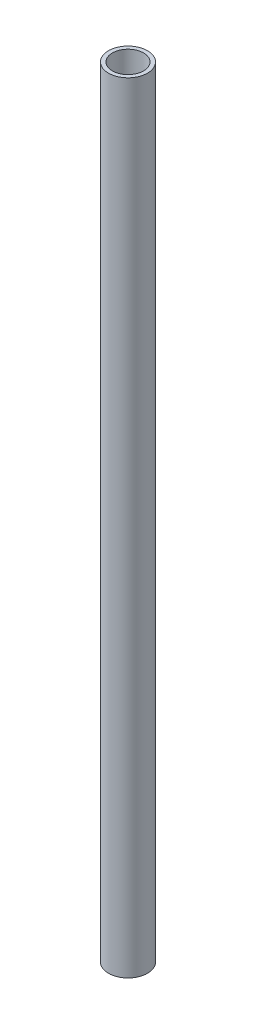
from build123d import *

# Parameters (mm, degrees)
SKETCH1_R           = 5
SKETCH1_R_2         = 4
EXTRUDE_THIN1_DEPTH = 200


with BuildPart() as part:
    # Sketch1 → Extrude-Thin1 (new body)
    with BuildSketch(Plane(origin=(0, 0, 0), x_dir=(1, 0, 0), z_dir=(0, 1, 0))):
        Circle(SKETCH1_R)
        Circle(SKETCH1_R_2, mode=Mode.SUBTRACT)
    extrude(amount=EXTRUDE_THIN1_DEPTH)


solid = part.part
